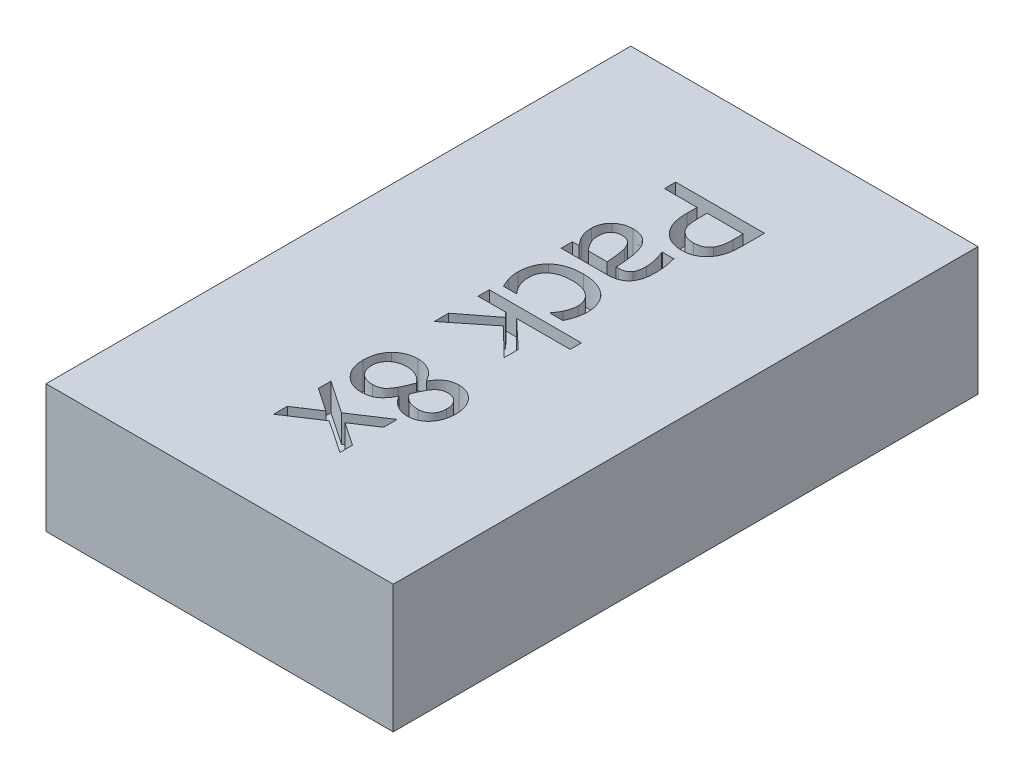
from build123d import *

# Parameters (mm, degrees)
SKETCH1_W           = 38
SKETCH1_H           = 14
BOSS_EXTRUDE1_DEPTH = 64
CUT_EXTRUDE1_DEPTH  = 3


with BuildPart() as part:
    # Sketch1 → Boss-Extrude1 (new body)
    with BuildSketch(Plane.XY):
        Rectangle(SKETCH1_W, SKETCH1_H)
    extrude(amount=BOSS_EXTRUDE1_DEPTH)

    # Sketch2 → Cut-Extrude1 (cut)
    with BuildSketch(Plane(origin=(0, 7, 0), x_dir=(1, 0, 0), z_dir=(0, 1, 0))):
        with BuildLine():
            add(Edge.make_bspline(
                [(3.10361678, -16.572975796), (2.998443262, -16.57079314), (2.789701001, -16.566461131), (2.481945704, -16.519553206), (2.182433634, -16.449727226), (1.894956664, -16.348711909), (1.62109005, -16.226161141), (1.368377071, -16.075844306), (1.132886678, -15.908271328), (0.994513388, -15.776338654), (0.925548373, -15.710583631)],
                knots=[0, 0, 0, 0, 0.000315281, 0.000625751, 0.000931823, 0.001236748, 0.00153845, 0.001830308, 0.002117675, 0.002403207, 0.002403207, 0.002403207, 0.002403207], degree=3))
            add(Edge.make_bspline(
                [(0.925548373, -15.710583631), (0.8444512, -15.624161024), (0.682418389, -15.451487953), (0.481465846, -15.157679588), (0.303598324, -14.846782778), (0.15788989, -14.508395602), (0.045773036, -14.134723403), (-0.033376913, -13.719722251), (-0.081152106, -13.259615991), (-0.086032535, -12.93786225), (-0.088578716, -12.769999212)],
                knots=[0, 0, 0, 0, 0.000355059, 0.00070941, 0.001064619, 0.001428544, 0.001811938, 0.002232693, 0.002694244, 0.0031977, 0.0031977, 0.0031977, 0.0031977], degree=3))
            Line((-0.088578716, -12.769999212), (-0.088578716, -11.65599597))
            Line((-0.088578716, -11.65599597), (-3.65338909, -11.65599597))
            Line((-3.65338909, -11.65599597), (-3.65338909, -10.426751014))
            Line((-3.65338909, -10.426751014), (6.057646066, -10.426751014))
            Line((6.057646066, -10.426751014), (6.057646066, -12.87179606))
            add(Edge.make_bspline(
                [(6.057646066, -12.87179606), (6.055749881, -13.010766357), (6.052102249, -13.278099228), (6.025951361, -13.662959983), (5.979987931, -14.015701109), (5.917427068, -14.338852115), (5.834539163, -14.637421786), (5.728349252, -14.915080955), (5.600921972, -15.175816336), (5.496543229, -15.335739567), (5.444944283, -15.414796564)],
                knots=[0, 0, 0, 0, 0.000416901, 0.000801981, 0.001156478, 0.001483436, 0.001788688, 0.002084755, 0.002374226, 0.002657221, 0.002657221, 0.002657221, 0.002657221], degree=3))
            add(Edge.make_bspline(
                [(5.444944283, -15.414796564), (5.380496835, -15.502358195), (5.252913325, -15.675699741), (5.024427162, -15.903917281), (4.77154826, -16.101836367), (4.495476692, -16.273384228), (4.190450776, -16.40958116), (3.854830634, -16.504519036), (3.489160986, -16.563013864), (3.235094824, -16.569578584), (3.10361678, -16.572975796)],
                knots=[0, 0, 0, 0, 0.000325794, 0.000644959, 0.00096503, 0.00128753, 0.001617694, 0.001963574, 0.00233113, 0.002725341, 0.002725341, 0.002725341, 0.002725341], degree=3))
        make_face()
        with BuildLine():
            add(Edge.make_bspline(
                [(3.072885656, -15.220806344), (3.155579742, -15.218551652), (3.31588274, -15.214180918), (3.547937185, -15.181722063), (3.762483389, -15.12594349), (3.960824494, -15.048762339), (4.142886745, -14.949431886), (4.304942324, -14.82353876), (4.454688409, -14.680064227), (4.534413723, -14.566072225), (4.574869337, -14.508228408)],
                knots=[0, 0, 0, 0, 0.000248038, 0.000480822, 0.000701176, 0.000911612, 0.001117942, 0.001320773, 0.001525856, 0.001737133, 0.001737133, 0.001737133, 0.001737133], degree=3))
            add(Edge.make_bspline(
                [(4.574869337, -14.508228408), (4.608359279, -14.455237455), (4.676355834, -14.347646874), (4.751814922, -14.169536232), (4.81959561, -13.98170145), (4.868163376, -13.777233209), (4.906979113, -13.55406941), (4.933117755, -13.307046583), (4.94779301, -13.03523735), (4.950117205, -12.845565476), (4.951325605, -12.746950869)],
                knots=[0, 0, 0, 0, 0.000187757, 0.000381214, 0.000578635, 0.000786399, 0.001010594, 0.00125791, 0.001531081, 0.001826924, 0.001826924, 0.001826924, 0.001826924], degree=3))
            Line((4.951325605, -12.746950869), (4.951325605, -11.65599597))
            Line((4.951325605, -11.65599597), (1.017741744, -11.65599597))
            Line((1.017741744, -11.65599597), (1.017741744, -12.552960649))
            add(Edge.make_bspline(
                [(1.017741744, -12.552960649), (1.018866537, -12.679775064), (1.021004993, -12.92087468), (1.046214215, -13.263289734), (1.085409561, -13.567531981), (1.139967578, -13.837538554), (1.216532961, -14.078239139), (1.320406851, -14.294885311), (1.447485274, -14.492191631), (1.553143957, -14.605677068), (1.605474489, -14.661884028)],
                knots=[0, 0, 0, 0, 0.000380375, 0.00072317, 0.001029308, 0.001300153, 0.001548577, 0.001784831, 0.002019226, 0.002249237, 0.002249237, 0.002249237, 0.002249237], degree=3))
            add(Edge.make_bspline(
                [(1.605474489, -14.661884028), (1.655008778, -14.70859524), (1.752304784, -14.800346116), (1.914103907, -14.914584494), (2.078601423, -15.014109872), (2.252634325, -15.092396323), (2.438027877, -15.149667957), (2.636556687, -15.192033506), (2.85008224, -15.21707141), (2.997270994, -15.219538788), (3.072885656, -15.220806344)],
                knots=[0, 0, 0, 0, 0.00020401, 0.00040072, 0.00059276, 0.000780173, 0.000971521, 0.001173815, 0.00138847, 0.001615242, 0.001615242, 0.001615242, 0.001615242], degree=3))
        make_face(mode=Mode.SUBTRACT)
        with BuildLine():
            add(Edge.make_bspline(
                [(-2.925445593, -21.735804613), (-2.945982411, -21.708952215), (-2.990400503, -21.650874463), (-3.060855181, -21.556448275), (-3.143527731, -21.450830592), (-3.267551036, -21.299494253), (-3.411721675, -21.103311163), (-3.50516219, -20.934579135), (-3.549671547, -20.854205496)],
                knots=[0, 0, 0, 0, 0.000101416, 0.000219347, 0.000353438, 0.00050372, 0.000806484, 0.001081888, 0.001081888, 0.001081888, 0.001081888], degree=3))
            add(Edge.make_bspline(
                [(-3.549671547, -20.854205496), (-3.600751306, -20.749379572), (-3.699574113, -20.546575323), (-3.798194145, -20.281392001), (-3.85504091, -20.055812477), (-3.878313705, -19.858503429), (-3.896872434, -19.631717258), (-3.898415389, -19.470717524), (-3.899238081, -19.384873634)],
                knots=[0, 0, 0, 0, 0.000349725, 0.000676604, 0.000846637, 0.001046288, 0.001271673, 0.001529111, 0.001529111, 0.001529111, 0.001529111], degree=3))
            add(Edge.make_bspline(
                [(-3.899238081, -19.384873634), (-3.896713344, -19.311155605), (-3.891708142, -19.165012232), (-3.861058937, -18.948434964), (-3.806593991, -18.738163092), (-3.731286841, -18.534531201), (-3.638086611, -18.339220673), (-3.525339797, -18.155800599), (-3.397476152, -17.983326975), (-3.297966901, -17.880577855), (-3.248122394, -17.829110486)],
                knots=[0, 0, 0, 0, 0.00022118, 0.000438482, 0.000654635, 0.000871572, 0.001088916, 0.001302701, 0.001516666, 0.001731407, 0.001731407, 0.001731407, 0.001731407], degree=3))
            add(Edge.make_bspline(
                [(-3.248122394, -17.829110486), (-3.195190927, -17.781979603), (-3.088365894, -17.686861171), (-2.909853282, -17.561215813), (-2.713175253, -17.451970653), (-2.50071967, -17.359039665), (-2.27714867, -17.281099161), (-2.044440893, -17.228725458), (-1.806060741, -17.194317913), (-1.645103272, -17.189855746), (-1.563672664, -17.187598274)],
                knots=[0, 0, 0, 0, 0.000212495, 0.000428853, 0.000653278, 0.000886325, 0.001123816, 0.001362361, 0.001600853, 0.001845053, 0.001845053, 0.001845053, 0.001845053], degree=3))
            add(Edge.make_bspline(
                [(-1.563672664, -17.187598274), (-1.441134775, -17.190912661), (-1.203470034, -17.197340983), (-0.861576413, -17.257442979), (-0.547553505, -17.357399897), (-0.262144092, -17.499356764), (-0.000861295, -17.6811722), (0.225845481, -17.914944627), (0.430053718, -18.19013364), (0.53377021, -18.400200424), (0.58750601, -18.509036603)],
                knots=[0, 0, 0, 0, 0.000367355, 0.000712493, 0.001037454, 0.001352694, 0.001665508, 0.001987389, 0.002325453, 0.002688917, 0.002688917, 0.002688917, 0.002688917], degree=3))
            add(Edge.make_bspline(
                [(0.58750601, -18.509036603), (0.632876783, -18.614615412), (0.726001235, -18.831318106), (0.833758979, -19.178856557), (0.920239087, -19.553235484), (0.98263081, -19.953623212), (1.033160477, -20.375446443), (1.07725935, -20.814746729), (1.113994387, -21.270032255), (1.131681694, -21.578906889), (1.14066624, -21.735804613)],
                knots=[0, 0, 0, 0, 0.000344549, 0.000707195, 0.001089703, 0.001496405, 0.001922128, 0.00236418, 0.002820846, 0.003292297, 0.003292297, 0.003292297, 0.003292297], degree=3))
            Line((1.14066624, -21.735804613), (1.376911755, -21.735804613))
            add(Edge.make_bspline(
                [(1.376911755, -21.735804613), (1.446154998, -21.734725631), (1.577467006, -21.732679462), (1.763981015, -21.706854866), (1.930006823, -21.667882119), (2.076655142, -21.611592383), (2.204942524, -21.540486316), (2.314998571, -21.453849757), (2.413863626, -21.358861941), (2.46400966, -21.28355038), (2.488994302, -21.246027326)],
                knots=[0, 0, 0, 0, 0.000207577, 0.000393647, 0.00056368, 0.000718126, 0.000863453, 0.001001756, 0.00113757, 0.00127243, 0.00127243, 0.00127243, 0.00127243], degree=3))
            add(Edge.make_bspline(
                [(2.488994302, -21.246027326), (2.513045753, -21.206222506), (2.562646084, -21.124134642), (2.618906784, -20.988310107), (2.661548037, -20.83927713), (2.700334822, -20.623109656), (2.732973489, -20.33914793), (2.736767007, -20.108439604), (2.738684684, -19.991813331)],
                knots=[0, 0, 0, 0, 0.000139366, 0.000287409, 0.000439375, 0.000603614, 0.000945741, 0.001295497, 0.001295497, 0.001295497, 0.001295497], degree=3))
            add(Edge.make_bspline(
                [(2.738684684, -19.991813331), (2.737048459, -19.918778223), (2.733639545, -19.766616638), (2.709435843, -19.529238103), (2.66811869, -19.273719081), (2.59320855, -18.905950749), (2.467590676, -18.430475746), (2.321243563, -18.060840334), (2.246986701, -17.873286477)],
                knots=[0, 0, 0, 0, 0.000219094, 0.000456461, 0.000715078, 0.000995329, 0.001582399, 0.002187113, 0.002187113, 0.002187113, 0.002187113], degree=3))
            Line((2.246986701, -17.873286477), (2.246986701, -17.802220753))
            Line((2.246986701, -17.802220753), (3.508883477, -17.802220753))
            add(Edge.make_bspline(
                [(3.508883477, -17.802220753), (3.52582871, -17.864245052), (3.562909546, -17.99997129), (3.616290398, -18.222807603), (3.6714107, -18.482281055), (3.728319541, -18.771386557), (3.779651124, -19.077904635), (3.819273063, -19.389777792), (3.839797295, -19.700225602), (3.843277553, -19.90663732), (3.845005144, -20.009099589)],
                knots=[0, 0, 0, 0, 0.000192884, 0.000422083, 0.000687292, 0.00098864, 0.001305979, 0.001619494, 0.001931363, 0.00223877, 0.00223877, 0.00223877, 0.00223877], degree=3))
            add(Edge.make_bspline(
                [(3.845005144, -20.009099589), (3.843379987, -20.128201848), (3.84025799, -20.357002299), (3.820880347, -20.685549536), (3.781457259, -20.984825977), (3.731113464, -21.258919653), (3.660234448, -21.512396889), (3.563785798, -21.748962224), (3.449143506, -21.975358734), (3.350655072, -22.112758427), (3.30144839, -22.18140591)],
                knots=[0, 0, 0, 0, 0.000357332, 0.00068645, 0.000986625, 0.001262364, 0.001521971, 0.001774489, 0.002027919, 0.002280963, 0.002280963, 0.002280963, 0.002280963], degree=3))
            add(Edge.make_bspline(
                [(3.30144839, -22.18140591), (3.249318627, -22.244417769), (3.145059099, -22.370441486), (2.958828564, -22.531711007), (2.750691968, -22.667749818), (2.519910039, -22.777567598), (2.264923728, -22.861994438), (1.984985128, -22.922942498), (1.678150092, -22.959509169), (1.464728468, -22.963155453), (1.353863412, -22.96504957)],
                knots=[0, 0, 0, 0, 0.000245007, 0.000490014, 0.000735601, 0.000989031, 0.001254455, 0.001539657, 0.001847221, 0.002179701, 0.002179701, 0.002179701, 0.002179701], degree=3))
            Line((1.353863412, -22.96504957), (-3.65338909, -22.96504957))
            Line((-3.65338909, -22.96504957), (-3.65338909, -21.735804613))
            Line((-3.65338909, -21.735804613), (-2.925445593, -21.735804613))
        make_face()
        with BuildLine():
            Line((-1.915159894, -21.735804613), (0.157270275, -21.735804613))
            add(Edge.make_bspline(
                [(0.157270275, -21.735804613), (0.150509513, -21.657668957), (0.136202947, -21.492324733), (0.107450371, -21.230138129), (0.080430919, -20.93915865), (0.046061134, -20.629321331), (0.010553869, -20.320216394), (-0.032789784, -20.032958618), (-0.083284332, -19.777373967), (-0.127353587, -19.620252244), (-0.148120269, -19.546212035)],
                knots=[0, 0, 0, 0, 0.000235275, 0.00049787, 0.000791234, 0.001111938, 0.00143308, 0.001724551, 0.001983332, 0.002213952, 0.002213952, 0.002213952, 0.002213952], degree=3))
            add(Edge.make_bspline(
                [(-0.148120269, -19.546212035), (-0.175122967, -19.467391314), (-0.227942963, -19.313210047), (-0.336089674, -19.09859054), (-0.467113632, -18.907295285), (-0.613051027, -18.733140081), (-0.789491559, -18.589305714), (-0.999885795, -18.488490525), (-1.239915364, -18.425353822), (-1.41087519, -18.419765832), (-1.500289721, -18.416843231)],
                knots=[0, 0, 0, 0, 0.000249757, 0.00048855, 0.000718151, 0.00094419, 0.001168262, 0.001395034, 0.001639144, 0.001906811, 0.001906811, 0.001906811, 0.001906811], degree=3))
            add(Edge.make_bspline(
                [(-1.500289721, -18.416843231), (-1.552173682, -18.41809424), (-1.652337769, -18.420509364), (-1.798540161, -18.435004615), (-1.933905448, -18.46432513), (-2.060931867, -18.50255467), (-2.177342071, -18.552384231), (-2.285482665, -18.611923601), (-2.381008277, -18.685946087), (-2.497913441, -18.796603276), (-2.619830867, -18.966608919), (-2.720723097, -19.210252716), (-2.782271722, -19.493272376), (-2.789237172, -19.695048678), (-2.792917621, -19.801664502)],
                knots=[0, 0, 0, 0, 0.000155683, 0.000300552, 0.000439932, 0.000570553, 0.000697914, 0.000819177, 0.000939799, 0.001059346, 0.001301384, 0.001560393, 0.001845595, 0.00216513, 0.00216513, 0.00216513, 0.00216513], degree=3))
            add(Edge.make_bspline(
                [(-2.792917621, -19.801664502), (-2.790338328, -19.89666017), (-2.785284182, -20.082805026), (-2.734372285, -20.35464247), (-2.65759642, -20.613819928), (-2.542322998, -20.856652733), (-2.40755979, -21.088263307), (-2.256140503, -21.311392436), (-2.093949397, -21.529160721), (-1.974929003, -21.666723817), (-1.915159894, -21.735804613)],
                knots=[0, 0, 0, 0, 0.000284678, 0.000557829, 0.00082698, 0.001093396, 0.001361889, 0.001630374, 0.001901961, 0.002175921, 0.002175921, 0.002175921, 0.002175921], degree=3))
        make_face(mode=Mode.SUBTRACT)
        with BuildLine():
            add(Edge.make_bspline(
                [(-3.776313586, -27.580480242), (-3.773133966, -27.458084945), (-3.76690517, -27.218315601), (-3.72464484, -26.8657807), (-3.651148623, -26.529902855), (-3.551978468, -26.208869464), (-3.422209997, -25.906494008), (-3.258666417, -25.626790401), (-3.06955097, -25.365711919), (-2.91857933, -25.21363427), (-2.842855697, -25.137355891)],
                knots=[0, 0, 0, 0, 0.000367174, 0.000719286, 0.00106324, 0.001397353, 0.001725971, 0.00204783, 0.002367826, 0.002689845, 0.002689845, 0.002689845, 0.002689845], degree=3))
            add(Edge.make_bspline(
                [(-2.842855697, -25.137355891), (-2.761159809, -25.065019786), (-2.595106957, -24.917991374), (-2.312715252, -24.729777097), (-1.998065191, -24.571292593), (-1.655638859, -24.433642991), (-1.280264839, -24.326998431), (-0.874330727, -24.248392496), (-0.436636546, -24.202567236), (-0.134784743, -24.19710947), (0.020900913, -24.194294526)],
                knots=[0, 0, 0, 0, 0.000327083, 0.000664819, 0.001014433, 0.001382511, 0.001770339, 0.002183186, 0.002621614, 0.003088596, 0.003088596, 0.003088596, 0.003088596], degree=3))
            add(Edge.make_bspline(
                [(0.020900913, -24.194294526), (0.175332538, -24.196904744), (0.47475047, -24.201965533), (0.907218378, -24.250433732), (1.30771459, -24.329374575), (1.674340902, -24.444767523), (2.012132905, -24.582348218), (2.320543775, -24.745129617), (2.603859912, -24.925689549), (2.771495839, -25.067583347), (2.853926398, -25.137355891)],
                knots=[0, 0, 0, 0, 0.000463143, 0.000897958, 0.001303644, 0.001685765, 0.002049224, 0.002396312, 0.002730872, 0.003054536, 0.003054536, 0.003054536, 0.003054536], degree=3))
            add(Edge.make_bspline(
                [(2.853926398, -25.137355891), (2.930863869, -25.211032725), (3.085687264, -25.35929465), (3.28219843, -25.617447259), (3.452793351, -25.900207769), (3.593543692, -26.207359385), (3.706513001, -26.53209856), (3.787479059, -26.871100619), (3.836829492, -27.221763672), (3.842258219, -27.459955588), (3.845005144, -27.580480242)],
                knots=[0, 0, 0, 0, 0.000319165, 0.000642265, 0.000969685, 0.001308273, 0.001653897, 0.001999563, 0.002352412, 0.00271383, 0.00271383, 0.00271383, 0.00271383], degree=3))
            add(Edge.make_bspline(
                [(3.845005144, -27.580480242), (3.843595679, -27.679828609), (3.840805166, -27.876522314), (3.80517833, -28.16824908), (3.755601941, -28.455235535), (3.678598159, -28.733778104), (3.591084967, -29.001755347), (3.49555897, -29.256846369), (3.398340357, -29.498665062), (3.322878187, -29.65141564), (3.286082828, -29.72589683)],
                knots=[0, 0, 0, 0, 0.000297863, 0.00058972, 0.000880564, 0.001170818, 0.001455684, 0.00172612, 0.001987927, 0.002237063, 0.002237063, 0.002237063, 0.002237063], degree=3))
            Line((3.286082828, -29.72589683), (1.878213214, -29.72589683))
            Line((1.878213214, -29.72589683), (1.878213214, -29.652910411))
            add(Edge.make_bspline(
                [(1.878213214, -29.652910411), (1.917692853, -29.603295983), (2.004633208, -29.494037233), (2.137786193, -29.306110269), (2.281812363, -29.077491993), (2.370643352, -28.905251275), (2.417928578, -28.813566589)],
                knots=[0, 0, 0, 0, 0.000190188, 0.000418823, 0.00069062, 0.000999965, 0.000999965, 0.000999965, 0.000999965], degree=3))
            add(Edge.make_bspline(
                [(2.417928578, -28.813566589), (2.460271095, -28.721502308), (2.550131317, -28.526121464), (2.646891944, -28.208715498), (2.725488318, -27.87730845), (2.734383384, -27.651337071), (2.738684684, -27.542066337)],
                knots=[0, 0, 0, 0, 0.000303652, 0.000644417, 0.000994005, 0.001321336, 0.001321336, 0.001321336, 0.001321336], degree=3))
            add(Edge.make_bspline(
                [(2.738684684, -27.542066337), (2.736421982, -27.463846646), (2.73200583, -27.311183991), (2.698833138, -27.087554492), (2.643056462, -26.876477538), (2.566673558, -26.675504612), (2.462755882, -26.489737983), (2.342356014, -26.312620594), (2.195384364, -26.150547854), (2.029222437, -25.999478159), (1.84269733, -25.86218498), (1.635567397, -25.745633977), (1.411258818, -25.645129452), (1.16888256, -25.562829649), (0.907925028, -25.49935408), (0.628356085, -25.456421338), (0.330674778, -25.42907334), (0.125961404, -25.425416303), (0.020900913, -25.423539483)],
                knots=[0, 0, 0, 0, 0.000234608, 0.000457888, 0.000676384, 0.00088861, 0.001100914, 0.001313496, 0.001529785, 0.001755498, 0.001986381, 0.002222946, 0.002467109, 0.002722821, 0.002989749, 0.003271732, 0.003570652, 0.003885792, 0.003885792, 0.003885792, 0.003885792], degree=3))
            add(Edge.make_bspline(
                [(0.020900913, -25.423539483), (-0.082214448, -25.425670553), (-0.282989273, -25.429819936), (-0.575220198, -25.453625277), (-0.849776505, -25.498523101), (-1.107042336, -25.55874329), (-1.347083309, -25.63850268), (-1.570941376, -25.732891207), (-1.77477362, -25.850004271), (-1.962860636, -25.979212104), (-2.12722459, -26.12827031), (-2.273814473, -26.288471029), (-2.397065849, -26.464010098), (-2.497872931, -26.653645361), (-2.574457332, -26.857265253), (-2.630566611, -27.073463049), (-2.663231965, -27.303547972), (-2.667703499, -27.461293513), (-2.669993125, -27.542066337)],
                knots=[0, 0, 0, 0, 0.000309381, 0.000602393, 0.000878686, 0.001143296, 0.001394143, 0.00163676, 0.001870707, 0.002098234, 0.002319948, 0.002534808, 0.002748489, 0.002961574, 0.003177385, 0.003399597, 0.00363048, 0.003872762, 0.003872762, 0.003872762, 0.003872762], degree=3))
            add(Edge.make_bspline(
                [(-2.669993125, -27.542066337), (-2.666939154, -27.641465233), (-2.660879708, -27.838684552), (-2.615248629, -28.131041882), (-2.540617668, -28.416422229), (-2.434370618, -28.691518476), (-2.304586553, -28.954174772), (-2.159814817, -29.20472892), (-1.993974319, -29.437828158), (-1.870802665, -29.581453283), (-1.809521655, -29.652910411)],
                knots=[0, 0, 0, 0, 0.000298104, 0.000591474, 0.000885441, 0.001181508, 0.001474426, 0.001763654, 0.002048779, 0.002331095, 0.002331095, 0.002331095, 0.002331095], degree=3))
            Line((-1.809521655, -29.652910411), (-1.809521655, -29.72589683))
            Line((-1.809521655, -29.72589683), (-3.205867098, -29.72589683))
            add(Edge.make_bspline(
                [(-3.205867098, -29.72589683), (-3.237322712, -29.657425939), (-3.306826679, -29.506133434), (-3.413269452, -29.269471808), (-3.515943846, -29.02362028), (-3.565094892, -28.855644562), (-3.588085452, -28.77707338)],
                knots=[0, 0, 0, 0, 0.000226039, 0.000499453, 0.000778721, 0.00102415, 0.00102415, 0.00102415, 0.00102415], degree=3))
            add(Edge.make_bspline(
                [(-3.588085452, -28.77707338), (-3.61569276, -28.678681658), (-3.667593446, -28.493708979), (-3.722198718, -28.263001836), (-3.751614443, -28.079758514), (-3.766774177, -27.929082067), (-3.773294984, -27.760440035), (-3.77527185, -27.642585372), (-3.776313586, -27.580480242)],
                knots=[0, 0, 0, 0, 0.00030659, 0.000576378, 0.000710579, 0.00086309, 0.001030367, 0.001216714, 0.001216714, 0.001216714, 0.001216714], degree=3))
        make_face()
        Polygon((-3.65338909, -36.855517578), (-3.65338909, -35.280547478), (-0.138516793, -32.568525792), (-0.620611299, -32.061462248), (-3.65338909, -32.061462248), (-3.65338909, -30.832217291), (6.426419553, -30.832217291), (6.426419553, -32.061462248), (0.570219753, -32.061462248), (3.599156153, -34.917536076), (3.599156153, -36.486744091), (0.566378362, -33.482776729), align=None)
        with BuildLine():
            add(Edge.make_bspline(
                [(-3.899238081, -44.415374061), (-3.896787685, -44.298089116), (-3.891992212, -44.068560183), (-3.85054106, -43.732456367), (-3.784005261, -43.41282127), (-3.690254343, -43.110148573), (-3.56888882, -42.827379562), (-3.424079013, -42.565061877), (-3.258204501, -42.32169255), (-3.125793611, -42.179424311), (-3.05989426, -42.108619072)],
                knots=[0, 0, 0, 0, 0.000351744, 0.00068837, 0.001014216, 0.00133011, 0.001637289, 0.001935591, 0.002228105, 0.002517926, 0.002517926, 0.002517926, 0.002517926], degree=3))
            add(Edge.make_bspline(
                [(-3.05989426, -42.108619072), (-2.992905662, -42.042851918), (-2.859867307, -41.912239333), (-2.633038713, -41.747010979), (-2.390450984, -41.603509959), (-2.12891634, -41.487328816), (-1.854673014, -41.395914115), (-1.571580913, -41.327433417), (-1.279831311, -41.289030008), (-1.082964858, -41.283559788), (-0.9836227, -41.280799421)],
                knots=[0, 0, 0, 0, 0.000281295, 0.000558648, 0.000839306, 0.001125593, 0.001415312, 0.001705547, 0.001998105, 0.002296116, 0.002296116, 0.002296116, 0.002296116], degree=3))
            add(Edge.make_bspline(
                [(-0.9836227, -41.280799421), (-0.853944344, -41.286220503), (-0.597407968, -41.296944766), (-0.219989468, -41.375163257), (0.139243749, -41.509872362), (0.422520022, -41.662104411), (0.637739722, -41.807014288), (0.790308757, -41.930790693), (0.937894416, -42.062851859), (1.074002614, -42.209389558), (1.200671349, -42.36847791), (1.322735079, -42.536986679), (1.433512544, -42.719236487), (1.499313421, -42.847036898), (1.53248807, -42.911469684)],
                knots=[0, 0, 0, 0, 0.000388911, 0.000769364, 0.001150403, 0.001536238, 0.001731215, 0.00192799, 0.002125149, 0.002324911, 0.002527086, 0.002734956, 0.002948741, 0.003166119, 0.003166119, 0.003166119, 0.003166119], degree=3))
            Line((1.53248807, -42.911469684), (1.570901975, -42.911469684))
            add(Edge.make_bspline(
                [(1.570901975, -42.911469684), (1.640521994, -42.799929485), (1.774134798, -42.585864637), (1.99997928, -42.299892387), (2.234720782, -42.05917315), (2.482208288, -41.860766933), (2.75405716, -41.709589254), (3.05328532, -41.601413744), (3.383921584, -41.53771311), (3.614235192, -41.530425513), (3.73360482, -41.526648413)],
                knots=[0, 0, 0, 0, 0.000394225, 0.000756585, 0.001090698, 0.001401168, 0.001704693, 0.002019429, 0.002352042, 0.002709915, 0.002709915, 0.002709915, 0.002709915], degree=3))
            add(Edge.make_bspline(
                [(3.73360482, -41.526648413), (3.824026587, -41.529227203), (4.0012261, -41.534280857), (4.261166384, -41.574241298), (4.509308305, -41.636734059), (4.746361673, -41.72632825), (4.972076193, -41.841092997), (5.183490458, -41.986153142), (5.387343001, -42.150543246), (5.573198584, -42.343668151), (5.745978621, -42.552001373), (5.894630179, -42.779468205), (6.021085908, -43.019369011), (6.126724962, -43.272769822), (6.203619488, -43.540706094), (6.26221544, -43.82108132), (6.297115842, -44.115504801), (6.301341495, -44.316685619), (6.303495057, -44.419215451)],
                knots=[0, 0, 0, 0, 0.000271152, 0.000531376, 0.000787124, 0.001037552, 0.0012901, 0.001544735, 0.001805419, 0.002074344, 0.002347326, 0.002616347, 0.002887845, 0.003159995, 0.003438343, 0.003722743, 0.004018636, 0.004326163, 0.004326163, 0.004326163, 0.004326163], degree=3))
            add(Edge.make_bspline(
                [(6.303495057, -44.419215451), (6.301279514, -44.525586392), (6.296957675, -44.733083191), (6.2633697, -45.036115818), (6.210754, -45.323663537), (6.133608507, -45.594820481), (6.035689353, -45.850602615), (5.914419958, -46.089278992), (5.771099761, -46.311564312), (5.608889304, -46.51676785), (5.428060775, -46.700055557), (5.236478657, -46.863819873), (5.02863133, -46.997996625), (4.811037085, -47.110603227), (4.580347811, -47.197961313), (4.337174548, -47.258040316), (4.08262317, -47.298883002), (3.908552806, -47.302341184), (3.820036106, -47.304099708)],
                knots=[0, 0, 0, 0, 0.000319044, 0.000622355, 0.000913548, 0.001195053, 0.00146685, 0.001733992, 0.001996651, 0.002259119, 0.002517179, 0.002768019, 0.003013606, 0.003257564, 0.003501923, 0.003751614, 0.004008039, 0.004273345, 0.004273345, 0.004273345, 0.004273345], degree=3))
            add(Edge.make_bspline(
                [(3.820036106, -47.304099708), (3.71083347, -47.299633967), (3.490910347, -47.290640414), (3.162803084, -47.217351904), (2.836559399, -47.101100125), (2.516181378, -46.941060668), (2.21310332, -46.738098704), (1.943352344, -46.487612031), (1.705824653, -46.199005386), (1.581874705, -45.980236537), (1.519043203, -45.869340361)],
                knots=[0, 0, 0, 0, 0.000327331, 0.000659211, 0.001003659, 0.001364422, 0.001730933, 0.002093863, 0.002465228, 0.002847003, 0.002847003, 0.002847003, 0.002847003], degree=3))
            Line((1.519043203, -45.869340361), (1.480629298, -45.869340361))
            add(Edge.make_bspline(
                [(1.480629298, -45.869340361), (1.412698038, -46.000075481), (1.28160981, -46.252357495), (1.051101447, -46.595394579), (0.795877506, -46.886236255), (0.56328213, -47.090888285), (0.363906989, -47.226007581), (0.205249122, -47.313182263), (0.036408923, -47.385491744), (-0.142851242, -47.445507678), (-0.331402737, -47.493814678), (-0.531475863, -47.525052083), (-0.74044537, -47.547919066), (-0.883679227, -47.549263166), (-0.956732967, -47.5499487)],
                knots=[0, 0, 0, 0, 0.000441777, 0.000852505, 0.001236279, 0.001599818, 0.001778277, 0.001957932, 0.002142038, 0.002328504, 0.002524622, 0.00272513, 0.002935549, 0.003154584, 0.003154584, 0.003154584, 0.003154584], degree=3))
            add(Edge.make_bspline(
                [(-0.956732967, -47.5499487), (-1.059316671, -47.547595152), (-1.260910248, -47.542970051), (-1.556466651, -47.499677699), (-1.838731351, -47.428062416), (-2.10863553, -47.330134158), (-2.366330054, -47.204229957), (-2.611264591, -47.050000974), (-2.842184227, -46.866175642), (-3.057881349, -46.657486636), (-3.255472778, -46.428921305), (-3.425673189, -46.181730847), (-3.574611399, -45.922780813), (-3.69235853, -45.647710571), (-3.78606311, -45.359198731), (-3.849816499, -45.056522996), (-3.89203198, -44.74051716), (-3.896808583, -44.524994318), (-3.899238081, -44.415374061)],
                knots=[0, 0, 0, 0, 0.000307605, 0.000604494, 0.00089378, 0.001179964, 0.001464292, 0.001752582, 0.002046548, 0.002348104, 0.002651847, 0.002951284, 0.003247171, 0.003546535, 0.003847202, 0.004155741, 0.004473307, 0.004802021, 0.004802021, 0.004802021, 0.004802021], degree=3))
        make_face()
        with BuildLine():
            add(Edge.make_bspline(
                [(3.795067068, -46.074854752), (3.84829984, -46.074156178), (3.953290267, -46.072778387), (4.106585391, -46.04970321), (4.254010995, -46.018918612), (4.392738924, -45.969029926), (4.52636517, -45.909919507), (4.65335722, -45.836779605), (4.773042037, -45.749816961), (4.884200138, -45.649882386), (4.986354614, -45.53835111), (5.076864032, -45.415939488), (5.152373067, -45.281541993), (5.213625266, -45.137091432), (5.261503095, -44.982625269), (5.296728375, -44.818174741), (5.314831814, -44.643059739), (5.318315265, -44.522968046), (5.320099092, -44.461470746)],
                knots=[0, 0, 0, 0, 0.000159522, 0.000314623, 0.000464203, 0.000610593, 0.000755881, 0.000902157, 0.0010493, 0.001198918, 0.001349824, 0.001502335, 0.001654567, 0.001811183, 0.001972167, 0.002139046, 0.002314882, 0.002499429, 0.002499429, 0.002499429, 0.002499429], degree=3))
            add(Edge.make_bspline(
                [(5.320099092, -44.461470746), (5.319188051, -44.405070251), (5.317391471, -44.293848139), (5.297437275, -44.131398413), (5.266971515, -43.976540342), (5.224507513, -43.830046684), (5.171143197, -43.690563664), (5.103096272, -43.559881386), (5.024311893, -43.435724049), (4.932470531, -43.321477179), (4.830954439, -43.217697809), (4.720583726, -43.126411518), (4.601213712, -43.048523926), (4.471023093, -42.988229074), (4.334789024, -42.937040982), (4.189005236, -42.902475308), (4.034990793, -42.884064308), (3.929561999, -42.880591087), (3.875736268, -42.878817865)],
                knots=[0, 0, 0, 0, 0.000169119, 0.000333504, 0.000490203, 0.000642169, 0.000790548, 0.00093744, 0.001083426, 0.001231007, 0.001376334, 0.001518232, 0.001659947, 0.001802558, 0.001947784, 0.002095926, 0.002250778, 0.002412299, 0.002412299, 0.002412299, 0.002412299], degree=3))
            add(Edge.make_bspline(
                [(3.875736268, -42.878817865), (3.798036821, -42.880962969), (3.648422888, -42.885093468), (3.433021047, -42.929216929), (3.235653408, -42.998776347), (3.057373974, -43.102099572), (2.894434038, -43.232018509), (2.738921987, -43.386738592), (2.595693866, -43.573297041), (2.509014997, -43.710388686), (2.464025264, -43.78154463)],
                knots=[0, 0, 0, 0, 0.000232793, 0.000448253, 0.000656655, 0.000857962, 0.001063144, 0.001280446, 0.001514432, 0.001766943, 0.001766943, 0.001766943, 0.001766943], degree=3))
            add(Edge.make_bspline(
                [(2.464025264, -43.78154463), (2.443282636, -43.818541975), (2.397191607, -43.900751698), (2.327498976, -44.039485016), (2.244214464, -44.203033506), (2.123268781, -44.447061385), (1.980639188, -44.751705723), (1.890039285, -45.001168969), (1.84748209, -45.11834852)],
                knots=[0, 0, 0, 0, 0.000127231, 0.000282712, 0.000465673, 0.000677838, 0.001099871, 0.001473717, 0.001473717, 0.001473717, 0.001473717], degree=3))
            add(Edge.make_bspline(
                [(1.84748209, -45.11834852), (1.918536304, -45.2058861), (2.054154739, -45.3729657), (2.27894442, -45.585215382), (2.504371591, -45.756205546), (2.738026587, -45.882251079), (2.982444384, -45.968887468), (3.238914353, -46.029246665), (3.511442973, -46.069823698), (3.698879307, -46.073148529), (3.795067068, -46.074854752)],
                knots=[0, 0, 0, 0, 0.000337911, 0.000644958, 0.000924998, 0.00118452, 0.001437884, 0.001700626, 0.001974155, 0.00226249, 0.00226249, 0.00226249, 0.00226249], degree=3))
        make_face(mode=Mode.SUBTRACT)
        with BuildLine():
            add(Edge.make_bspline(
                [(-1.077736767, -46.197779247), (-0.982860738, -46.194665522), (-0.80169191, -46.188719764), (-0.544896006, -46.148862441), (-0.320135418, -46.074330876), (-0.117527831, -45.972557847), (0.065269908, -45.819980811), (0.245341663, -45.622035517), (0.425528192, -45.369442643), (0.536076986, -45.178299709), (0.595188791, -45.076093225)],
                knots=[0, 0, 0, 0, 0.000284678, 0.000543602, 0.000776228, 0.000992713, 0.001219485, 0.001485902, 0.001794028, 0.00214813, 0.00214813, 0.00214813, 0.00214813], degree=3))
            add(Edge.make_bspline(
                [(0.595188791, -45.076093225), (0.616584721, -45.037182818), (0.66240111, -44.953861627), (0.7292958, -44.818410078), (0.795587148, -44.663681961), (0.893947683, -44.426695461), (1.026391612, -44.094804602), (1.143776418, -43.823494686), (1.205969878, -43.679747782)],
                knots=[0, 0, 0, 0, 0.000133208, 0.000285247, 0.000452964, 0.00063809, 0.00105504, 0.001524888, 0.001524888, 0.001524888, 0.001524888], degree=3))
            add(Edge.make_bspline(
                [(1.205969878, -43.679747782), (1.144561177, -43.598051994), (1.023514273, -43.437015824), (0.80950835, -43.22665365), (0.575072614, -43.046608668), (0.320865708, -42.895678975), (0.046213574, -42.778465296), (-0.246336258, -42.693202457), (-0.558049525, -42.642815007), (-0.772160396, -42.636303832), (-0.881825852, -42.632968874)],
                knots=[0, 0, 0, 0, 0.000306265, 0.0006037, 0.000896819, 0.001191306, 0.001488145, 0.001790232, 0.00210347, 0.002432363, 0.002432363, 0.002432363, 0.002432363], degree=3))
            add(Edge.make_bspline(
                [(-0.881825852, -42.632968874), (-0.95360966, -42.634237492), (-1.09506881, -42.636737468), (-1.301896461, -42.662571056), (-1.499171095, -42.70269804), (-1.68716636, -42.758485883), (-1.865454154, -42.831109869), (-2.033904362, -42.921014525), (-2.194307451, -43.023715765), (-2.34073791, -43.145348994), (-2.475679459, -43.276707559), (-2.592046426, -43.419361592), (-2.694308965, -43.567773021), (-2.774828874, -43.727083067), (-2.83851946, -43.893709207), (-2.882620776, -44.069106713), (-2.910130179, -44.25188443), (-2.913918079, -44.376861755), (-2.915842116, -44.440343099)],
                knots=[0, 0, 0, 0, 0.000215255, 0.000424187, 0.000624207, 0.000818663, 0.001011624, 0.001200644, 0.001390831, 0.001581919, 0.001770705, 0.001954901, 0.002133361, 0.002310315, 0.002489033, 0.002667451, 0.002851887, 0.003042278, 0.003042278, 0.003042278, 0.003042278], degree=3))
            add(Edge.make_bspline(
                [(-2.915842116, -44.440343099), (-2.914435794, -44.505077885), (-2.911683421, -44.631773034), (-2.888118091, -44.816932291), (-2.849954624, -44.99255312), (-2.796454787, -45.158167729), (-2.726488242, -45.31419048), (-2.640076345, -45.459266491), (-2.539367097, -45.595400306), (-2.423716905, -45.719837802), (-2.29632369, -45.833695383), (-2.153846965, -45.929630597), (-2.001954309, -46.01329796), (-1.837660409, -46.079296426), (-1.664178722, -46.134897332), (-1.478296645, -46.16942495), (-1.281980582, -46.193872768), (-1.146964769, -46.196455155), (-1.077736767, -46.197779247)],
                knots=[0, 0, 0, 0, 0.000194142, 0.000379964, 0.000558919, 0.000732633, 0.000901129, 0.001070772, 0.001238258, 0.001408161, 0.001579631, 0.001749577, 0.001922333, 0.00209889, 0.002279925, 0.002467889, 0.002665151, 0.002872728, 0.002872728, 0.002872728, 0.002872728], degree=3))
        make_face(mode=Mode.SUBTRACT)
        Polygon((-3.65338909, -54.433720456), (-3.65338909, -52.943260946), (-1.104626501, -51.260731912), (-3.65338909, -49.543630363), (-3.65338909, -48.164571178), (-0.067451069, -50.580805795), (3.599156153, -48.164571178), (3.599156153, -49.656951383), (1.048472868, -51.335639026), (3.599156153, -53.056581966), (3.599156153, -54.433720456), (0.017059522, -52.017485838), align=None)
    extrude(amount=-CUT_EXTRUDE1_DEPTH, mode=Mode.SUBTRACT)


solid = part.part
